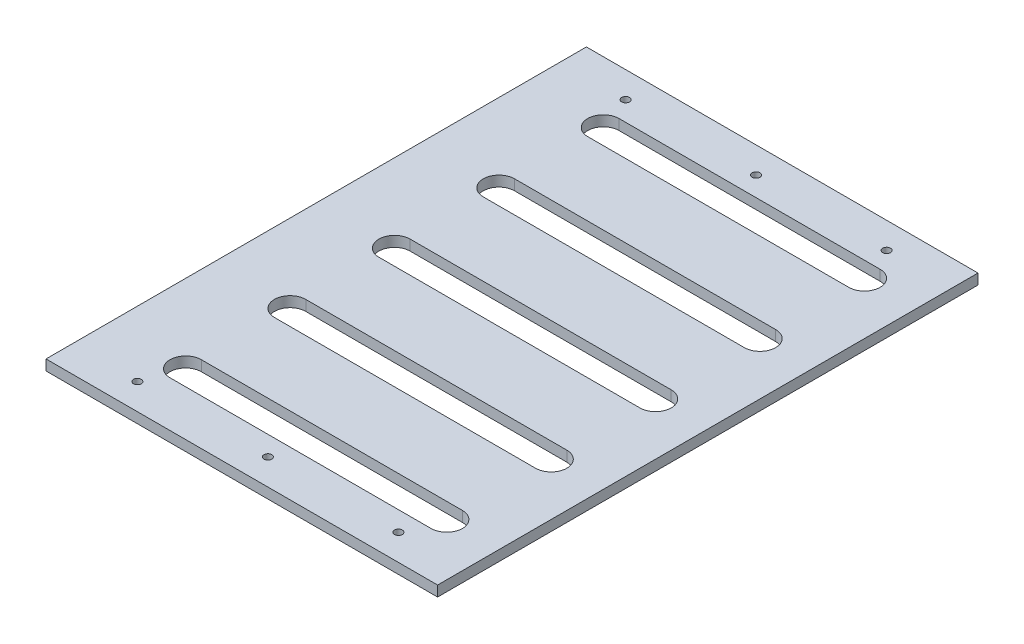
from build123d import *

# Parameters (mm, degrees)
SKETCH_1_W          = 150
SKETCH_1_H          = 207
EXTRUDE_1_DEPTH     = 4
CUT_EXTRUDE_1_DEPTH = 5
SKETCH_3_R          = 1.5
CUT_EXTRUDE_2_DEPTH = 5


with BuildPart() as part:
    # 草图1 → 凸台-拉伸1 (new body)
    with BuildSketch(Plane(origin=(0, 0, 0), x_dir=(1, 0, 0), z_dir=(0, 1, 0))):
        with Locations((75, 103.5)):
            Rectangle(SKETCH_1_W, SKETCH_1_H)
    extrude(amount=EXTRUDE_1_DEPTH)

    # 草图2 → 切除-拉伸1 (cut, through all)
    with BuildSketch(Plane(origin=(0, 4, 0), x_dir=(1, 0, 0), z_dir=(0, 1, 0))):
        with BuildLine():
            Line((30, 189.5), (130, 189.5))
            ThreePointArc((130, 189.5), (136, 183.5), (130, 177.5))
            Line((130, 177.5), (30, 177.5))
            ThreePointArc((30, 177.5), (24, 183.5), (30, 189.5))
        make_face()
        with BuildLine():
            Line((30, 149.5), (130, 149.5))
            ThreePointArc((130, 149.5), (136, 143.5), (130, 137.5))
            Line((130, 137.5), (30, 137.5))
            ThreePointArc((30, 137.5), (24, 143.5), (30, 149.5))
        make_face()
        with BuildLine():
            Line((30, 97.5), (130, 97.5))
            ThreePointArc((130, 97.5), (136, 103.5), (130, 109.5))
            Line((130, 109.5), (30, 109.5))
            ThreePointArc((30, 109.5), (24, 103.5), (30, 97.5))
        make_face()
        with BuildLine():
            Line((30, 57.5), (130, 57.5))
            ThreePointArc((130, 57.5), (136, 63.5), (130, 69.5))
            Line((130, 69.5), (30, 69.5))
            ThreePointArc((30, 69.5), (24, 63.5), (30, 57.5))
        make_face()
        with BuildLine():
            Line((30, 17.5), (130, 17.5))
            ThreePointArc((130, 17.5), (136, 23.5), (130, 29.5))
            Line((130, 29.5), (30, 29.5))
            ThreePointArc((30, 29.5), (24, 23.5), (30, 17.5))
        make_face()
    extrude(amount=-CUT_EXTRUDE_1_DEPTH, mode=Mode.SUBTRACT)

    # 草图3 → 切除-拉伸2 (cut, through all)
    with BuildSketch(Plane(origin=(0, 4, 0), x_dir=(1, 0, 0), z_dir=(0, 1, 0))):
        with Locations((125, 197)):
            Circle(SKETCH_3_R)
        with Locations((75, 197)):
            Circle(SKETCH_3_R)
        with Locations((25, 197)):
            Circle(SKETCH_3_R)
        with Locations((25, 10)):
            Circle(SKETCH_3_R)
        with Locations((75, 10)):
            Circle(SKETCH_3_R)
        with Locations((125, 10)):
            Circle(SKETCH_3_R)
    extrude(amount=-CUT_EXTRUDE_2_DEPTH, mode=Mode.SUBTRACT)


solid = part.part
